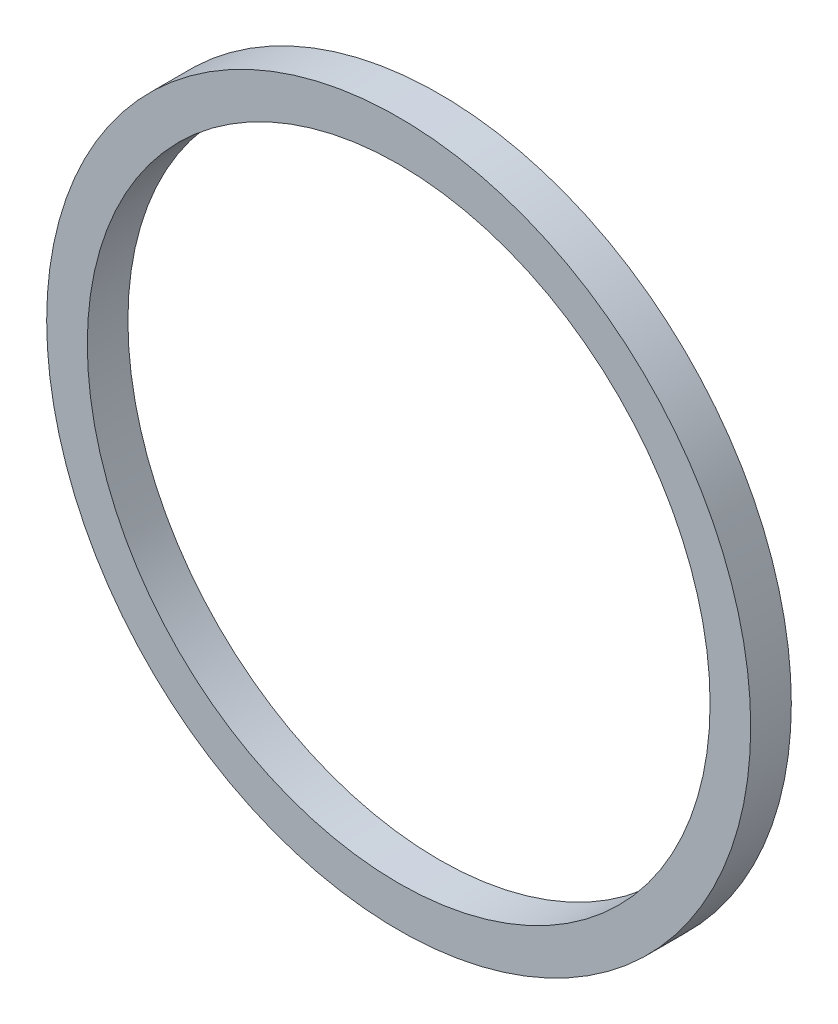
from build123d import *

# Parameters (mm, degrees)
SKETCH_1_R      = 13
SKETCH_1_R_2    = 11.5
EXTRUDE_1_DEPTH = 1.5


with BuildPart() as part:
    # Эскиз1 → Бобышка-Вытянуть1 (new body)
    with BuildSketch(Plane.XY):
        Circle(SKETCH_1_R)
        Circle(SKETCH_1_R_2, mode=Mode.SUBTRACT)
    extrude(amount=EXTRUDE_1_DEPTH)


solid = part.part
